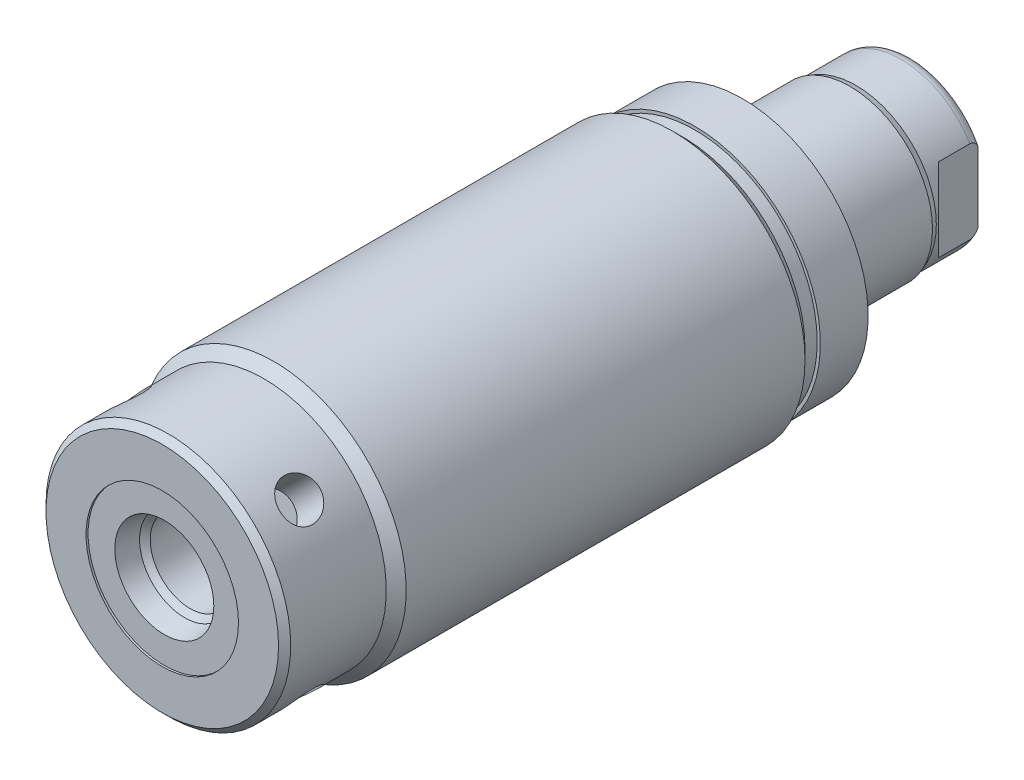
from build123d import *

# Parameters (mm, degrees)
SKETCH1_R          = 16.5354
EXTRUDE1_DEPTH     = 66.548
CHAMFER1_SIZE      = 0.762
SKETCH6_R          = 15.6845
EXTRUDE2_DEPTH     = 5.969
SKETCH7_W          = 20.828
SKETCH7_H          = 10.31875
CUT_EXTRUDE4_DEPTH = 19.84248
HOLE1_D            = 5.0038
HOLE1_DEPTH        = 4.7498
CIRPATTERN1_COUNT  = 4


with BuildPart() as part:
    # Sketch1 → Extrude1 (new body)
    with BuildSketch(Plane.XY):
        Circle(SKETCH1_R)
    extrude(amount=EXTRUDE1_DEPTH)

    # Sketch2 → Cut-Revolve1 (revolve, cut)
    with BuildSketch(Plane(origin=(0, 0, 0), x_dir=(1, 0, 0), z_dir=(0, 1, 0)), mode=Mode.PRIVATE) as cut_revolve1_sk:
        Polygon((16.5354, -66.548), (16.5354, -52.6034), (15.2908, -53.848), (15.2908, -66.548), align=None)
    revolve(cut_revolve1_sk.sketch.rotate(Axis((0, 0, 0), (0, 0, 1)), 180), axis=Axis((0, 0, 0), (0, 0, 1)), mode=Mode.SUBTRACT)  # turned: the seam where the file's is

    # Sketch3 → Cut-Revolve2 (revolve, cut)
    with BuildSketch(Plane(origin=(0, 0, 0), x_dir=(1, 0, 0), z_dir=(0, 1, 0)), mode=Mode.PRIVATE) as cut_revolve2_sk:
        Polygon((15.2908, 0), (15.2908, -1.524), (16.5354, -2.7686), (16.5354, 0), align=None)
    revolve(cut_revolve2_sk.sketch.rotate(Axis((0, 0, 0), (0, 0, -1)), 180), axis=Axis((0, 0, 0), (0, 0, -1)), mode=Mode.SUBTRACT)  # turned: the seam where the file's is

    # S2D0002 → Cut-Revolve3 (revolve, cut)
    with BuildSketch(Plane(origin=(0, 0, 0), x_dir=(1, 0, 0), z_dir=(0, 1, 0))):
        Polygon((6.1849, -66.294), (9.525, -66.294), (9.525, -66.548), (0, -66.548), (0, -52.324), (4.9784, -52.324), (4.9784, -63.077393135), (5.642306865, -63.7413), align=None)
    revolve(axis=Axis((0, 0, 14.6685), (0, 0, -1)), mode=Mode.SUBTRACT)

    # Chamfer1
    chamfer1_edges = [part.edges().sort_by_distance(p)[0] for p in [
        (15.2908, 0, 66.548),
    ]]
    chamfer(chamfer1_edges, length=CHAMFER1_SIZE)

    # Sketch6 → Extrude2 (add)
    with BuildSketch(Plane(origin=(0, 0, 0), x_dir=(-1, 0, 0), z_dir=(0, 0, -1))):
        Circle(SKETCH6_R)
    extrude(amount=EXTRUDE2_DEPTH)

    # Sketch7 → Revolve1 (revolve)
    with BuildSketch(Plane(origin=(0, 0, 0), x_dir=(0, 0, -1), z_dir=(1, 0, 0)), mode=Mode.PRIVATE) as revolve1_sk:
        with Locations((16.383, -5.159375)):
            Rectangle(SKETCH7_W, SKETCH7_H)
    revolve(revolve1_sk.sketch.rotate(Axis((0, 0, 0), (0, 0, -1)), 270), axis=Axis((0, 0, 0), (0, 0, -1)))  # turned: the seam where the file's is

    # S2D0001 → Cut-Revolve5 (revolve, cut)
    with BuildSketch(Plane(origin=(0, 0, 0), x_dir=(1, 0, 0), z_dir=(0, 1, 0))):
        Polygon((3.2639, 24.861260017), (3.2639, 11.9888), (0, 11.9888), (0, 26.797), (4.3815, 26.797), align=None)
    revolve(axis=Axis((0, 0, 31.308359971), (0, 0, -1)), mode=Mode.SUBTRACT)

    # Sketch9 → Cut-Revolve6 (revolve, cut)
    with BuildSketch(Plane(origin=(0, 0, 0), x_dir=(0, -1, 0), z_dir=(1, 0, 0)), mode=Mode.PRIVATE) as cut_revolve6_sk:
        with BuildLine():
            Line((-10.31875, 19.3802), (-10.033, 20.1422))
            Line((-10.033, 20.1422), (-10.033, 25.781))
            ThreePointArc((-10.033, 25.781), (-9.932678675, 26.324796865), (-9.644922533, 26.797))
            Line((-9.644922533, 26.797), (-10.31875, 26.797))
            Line((-10.31875, 26.797), (-10.31875, 19.3802))
        make_face()
    revolve(cut_revolve6_sk.sketch.rotate(Axis((0, 0, -12.65936), (0, 0, -1)), 90), axis=Axis((0, 0, -12.65936), (0, 0, -1)), mode=Mode.SUBTRACT)  # turned: the seam where the file's is

    # Sketch13 → Cut-Extrude4 (cut, symmetric)
    with BuildSketch(Plane(origin=(0, 0, 0), x_dir=(1, 0, 0), z_dir=(0, 1, 0))):
        Polygon((8.5852, 26.797), (8.5852, 21.844), (10.033, 20.3962), (10.033, 26.797), align=None)
        Polygon((-8.5852, 26.797), (-8.5852, 21.844), (-10.033, 20.3962), (-10.033, 26.797), align=None)
    extrude(amount=CUT_EXTRUDE4_DEPTH, both=True, mode=Mode.SUBTRACT)

    # Hole1
    with Locations(Plane(origin=(-10.81222837, 10.81222837, 60.198), x_dir=(0.707106781, 0.707106781, 0), z_dir=(-0.707106781, 0.707106781, 0))):
        with Locations((0, 0)):
            hole1 = Hole(HOLE1_D / 2, depth=HOLE1_DEPTH)

    # CirPattern1: Hole1 ×4 about axis
    cirpattern1_axis = Axis((0, 0, 0), (0, 0, 1))
    for i in range(1, CIRPATTERN1_COUNT):
        add(hole1.rotate(cirpattern1_axis, i * 360 / CIRPATTERN1_COUNT), mode=Mode.SUBTRACT)


solid = part.part
